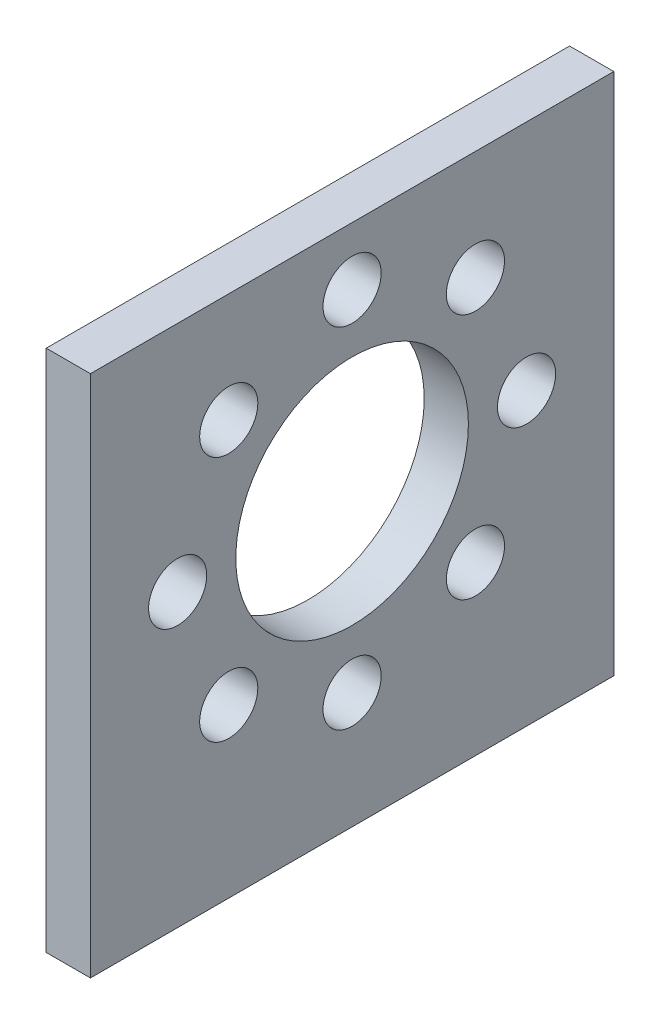
from build123d import *

# Parameters (mm, degrees)
SKETCH2_W           = 57.15
SKETCH2_H           = 57.15
SKETCH2_R           = 12.7
BOSS_EXTRUDE2_DEPTH = 4.826
SKETCH2_4_R         = 3.175
CUT_EXTRUDE4_DEPTH  = 60.896656138
CIRPATTERN1_COUNT   = 8


with BuildPart() as part:
    # Sketch2 → Boss-Extrude2 (new body)
    with BuildSketch(Plane(origin=(0, 0, 0), x_dir=(0, 0, -1), z_dir=(1, 0, 0))):
        with Locations((-19.436862591, 6.909929069)):
            Rectangle(SKETCH2_W, SKETCH2_H)
        with Locations((-19.436862591, 10.084929069)):
            Circle(SKETCH2_R, mode=Mode.SUBTRACT)
    extrude(amount=BOSS_EXTRUDE2_DEPTH)

    # Sketch2_4 → Cut-Extrude4 (cut, through all)
    with BuildSketch(Plane(origin=(0, 0, 0), x_dir=(0, 0, -1), z_dir=(1, 0, 0))):
        with Locations((-19.436862591, 29.134929069)):
            Circle(SKETCH2_4_R)
    cut_extrude4 = extrude(amount=CUT_EXTRUDE4_DEPTH, mode=Mode.SUBTRACT)

    # CirPattern1: Cut-Extrude4 ×8 about axis
    cirpattern1_axis = Axis((4.826, 10.084929069, 19.436862591), (-1, 0, 0))
    for i in range(1, CIRPATTERN1_COUNT):
        add(cut_extrude4.rotate(cirpattern1_axis, i * 360 / CIRPATTERN1_COUNT), mode=Mode.SUBTRACT)


solid = part.part
